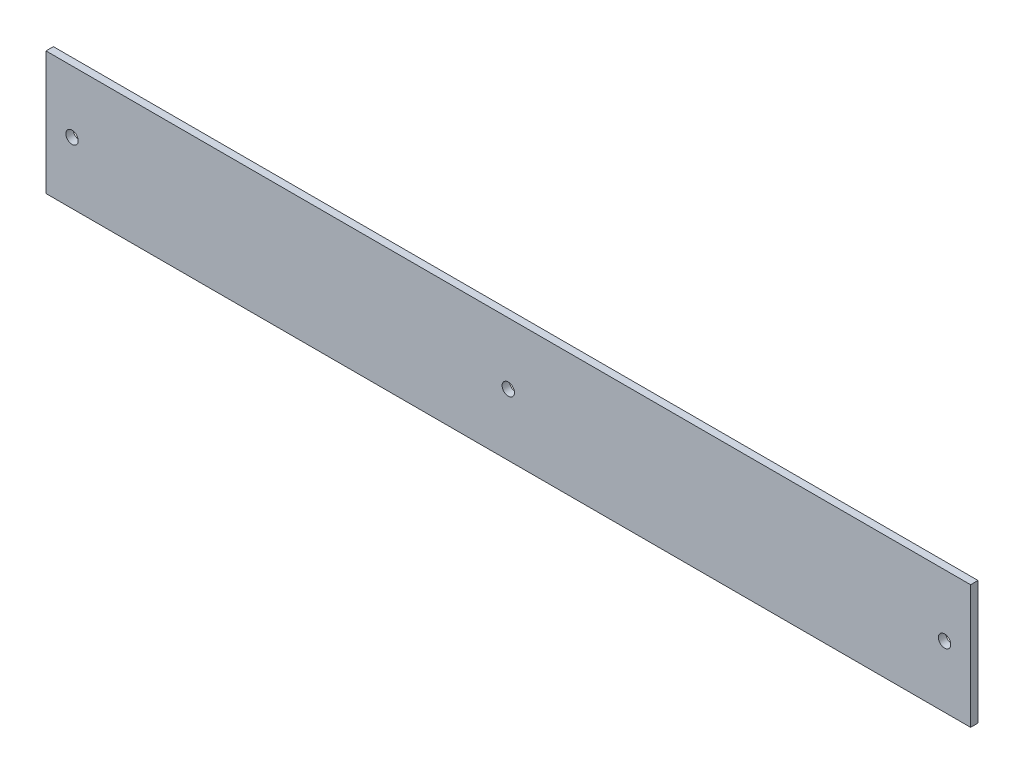
from build123d import *

# Parameters (mm, degrees)
SKETCH1_W           = 380.1872
SKETCH1_H           = 50.8
SKETCH1_R           = 2.54
BOSS_EXTRUDE1_DEPTH = 3.048


with BuildPart() as part:
    # Sketch1 → Boss-Extrude1 (new body)
    with BuildSketch(Plane.XY):
        with Locations((190.0936, 25.4)):
            Rectangle(SKETCH1_W, SKETCH1_H)
        with Locations((10.7061, 25.4)):
            Circle(SKETCH1_R, mode=Mode.SUBTRACT)
        with Locations((190.0936, 25.4)):
            Circle(SKETCH1_R, mode=Mode.SUBTRACT)
        with Locations((369.4811, 25.4)):
            Circle(SKETCH1_R, mode=Mode.SUBTRACT)
    extrude(amount=BOSS_EXTRUDE1_DEPTH)


solid = part.part
